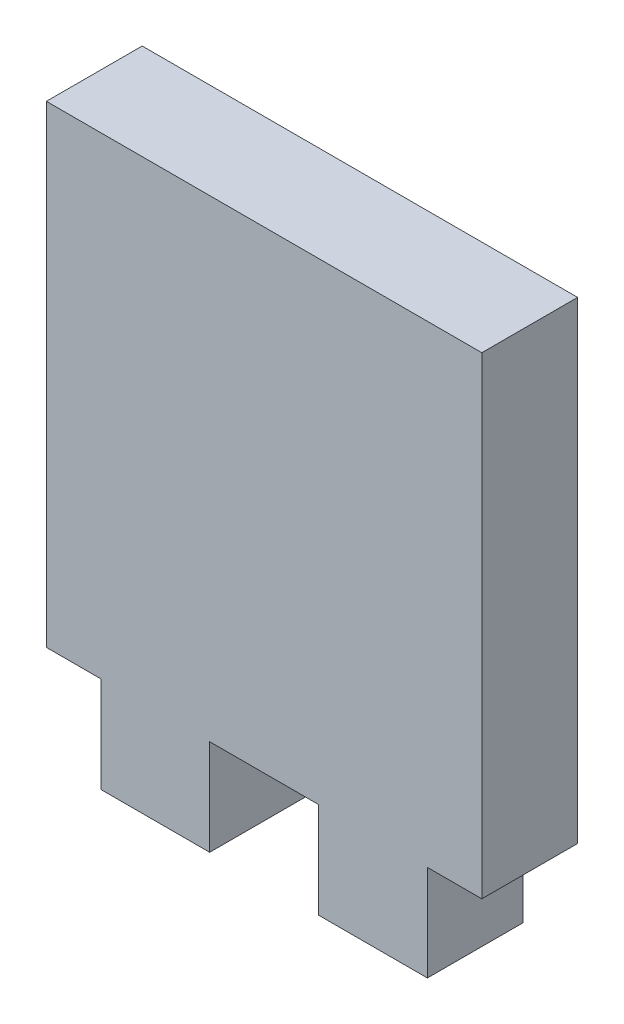
from build123d import *

# Parameters (mm, degrees)
BOSS_EXTRUDE1_DEPTH = 5.588


with BuildPart() as part:
    # Sketch1 → Boss-Extrude1 (new body)
    with BuildSketch(Plane.XY):
        Polygon((0, 0), (3.175, 0), (3.175, -5.588), (9.525, -5.588), (9.525, 0), (15.875, 0), (15.875, -5.588), (22.225, -5.588), (22.225, 0), (25.4, 0), (25.4, 27.588), (0, 27.588), align=None)
    extrude(amount=BOSS_EXTRUDE1_DEPTH)


solid = part.part
